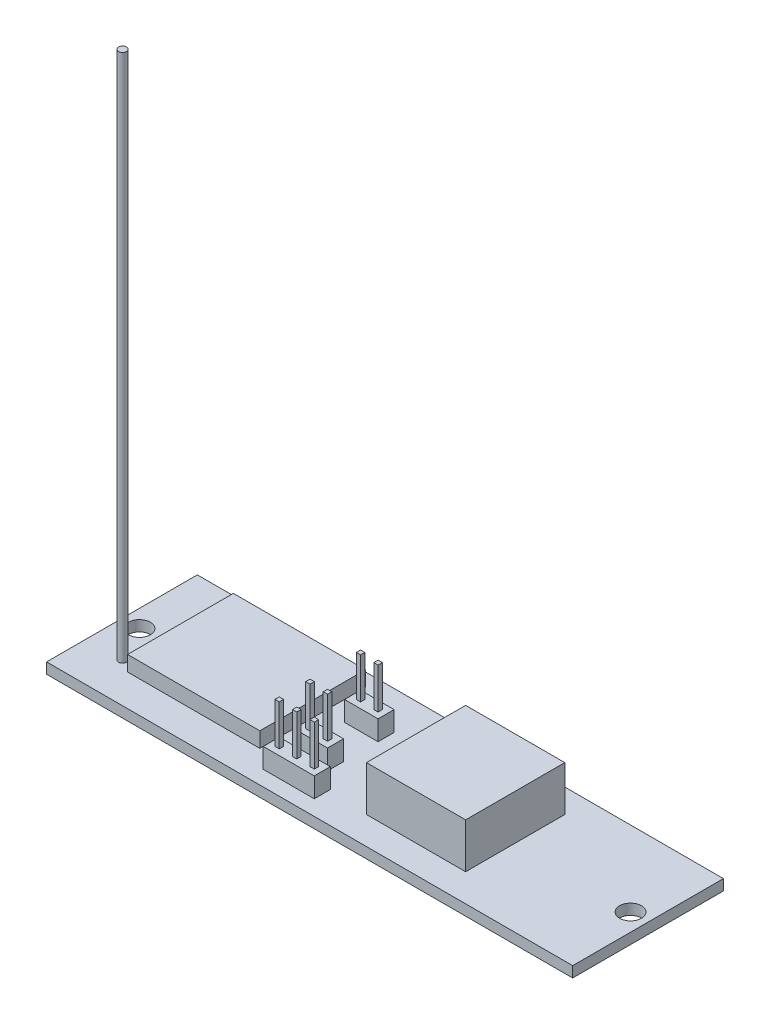
from build123d import *

# Parameters (mm, degrees)
SKETCH1_W              = 79.57
SKETCH1_H              = 22.8
SKETCH1_R              = 1.65
BOSS_EXTRUDE2_DEPTH    = 1.62
SKETCH2_W              = 15
SKETCH2_H              = 15
BOSS_EXTRUDE3_DEPTH    = 6.8
SKETCH3_W              = 0.65
SKETCH3_H              = 0.65
BOSS_EXTRUDE4_DEPTH    = 9.16
SKETCH4_W              = 7.72
SKETCH4_H              = 2.42
SKETCH4_W_2            = 5.07
SKETCH4_H_2            = 2.424
BOSS_EXTRUDE5_DEPTH    = 3
SKETCH5_W              = 20
SKETCH5_H              = 16
BOSS_EXTRUDE6_DEPTH    = 2.3
SKETCH6_R              = 0.45
HOLE_FOR_ANTENNA_DEPTH = 2.8
SKETCH7_R              = 0.6
BOSS_EXTRUDE7_DEPTH    = 80


with BuildPart() as part:
    # Sketch1 → Boss-Extrude2 (new body)
    with BuildSketch(Plane(origin=(0, 0, 0), x_dir=(1, 0, 0), z_dir=(0, 1, 0))):
        with Locations((39.785, 11.4)):
            Rectangle(SKETCH1_W, SKETCH1_H)
        with Locations((2.65, 11.4)):
            Circle(SKETCH1_R, mode=Mode.SUBTRACT)
        with Locations((76.92, 11.4)):
            Circle(SKETCH1_R, mode=Mode.SUBTRACT)
    extrude(amount=BOSS_EXTRUDE2_DEPTH)

    # Sketch2 → Boss-Extrude3 (add)
    with BuildSketch(Plane(origin=(0, 1.62, 0), x_dir=(1, 0, 0), z_dir=(0, 1, 0))):
        with Locations((51.68, 11.7)):
            Rectangle(SKETCH2_W, SKETCH2_H)
    extrude(amount=BOSS_EXTRUDE3_DEPTH)

    # Sketch3 → Boss-Extrude4 (add)
    with BuildSketch(Plane(origin=(0, 1.62, 0), x_dir=(1, 0, 0), z_dir=(0, 1, 0))):
        with Locations((31.665, 3.525)):
            Rectangle(SKETCH3_W, SKETCH3_H)
        with Locations((34.315, 3.525)):
            Rectangle(SKETCH3_W, SKETCH3_H)
        with Locations((36.965, 3.525)):
            Rectangle(SKETCH3_W, SKETCH3_H)
        with Locations((31.665, 8.175)):
            Rectangle(SKETCH3_W, SKETCH3_H)
        with Locations((34.315, 8.175)):
            Rectangle(SKETCH3_W, SKETCH3_H)
        with Locations((31.665, 15.825)):
            Rectangle(SKETCH3_W, SKETCH3_H)
        with Locations((34.315, 15.825)):
            Rectangle(SKETCH3_W, SKETCH3_H)
    extrude(amount=BOSS_EXTRUDE4_DEPTH)

    # Sketch4 → Boss-Extrude5 (add)
    with BuildSketch(Plane(origin=(0, 1.62, 0), x_dir=(1, 0, 0), z_dir=(0, 1, 0))):
        with Locations((34.315, 3.525)):
            Rectangle(SKETCH4_W, SKETCH4_H)
        with Locations((32.99, 8.175)):
            Rectangle(SKETCH4_W_2, SKETCH4_H)
        with Locations((32.99, 15.823)):
            Rectangle(SKETCH4_W_2, SKETCH4_H_2)
    extrude(amount=BOSS_EXTRUDE5_DEPTH)

    # Sketch5 → Boss-Extrude6 (add)
    with BuildSketch(Plane(origin=(0, 1.62, 0), x_dir=(1, 0, 0), z_dir=(0, 1, 0))):
        with Locations((17.45, 12.8)):
            Rectangle(SKETCH5_W, SKETCH5_H)
    extrude(amount=BOSS_EXTRUDE6_DEPTH)

    # Sketch6 → Hole for antenna (cut)
    with BuildSketch(Plane(origin=(0, 1.62, 0), x_dir=(1, 0, 0), z_dir=(0, 1, 0))):
        with Locations((5.5, 6)):
            Circle(SKETCH6_R)
    extrude(amount=-HOLE_FOR_ANTENNA_DEPTH, mode=Mode.SUBTRACT)

    # Sketch7 → Boss-Extrude7 (add)
    with BuildSketch(Plane(origin=(0, 1.62, 0), x_dir=(1, 0, 0), z_dir=(0, 1, 0))):
        with Locations((5.5, 6)):
            Circle(SKETCH7_R)
    extrude(amount=BOSS_EXTRUDE7_DEPTH)


solid = part.part
